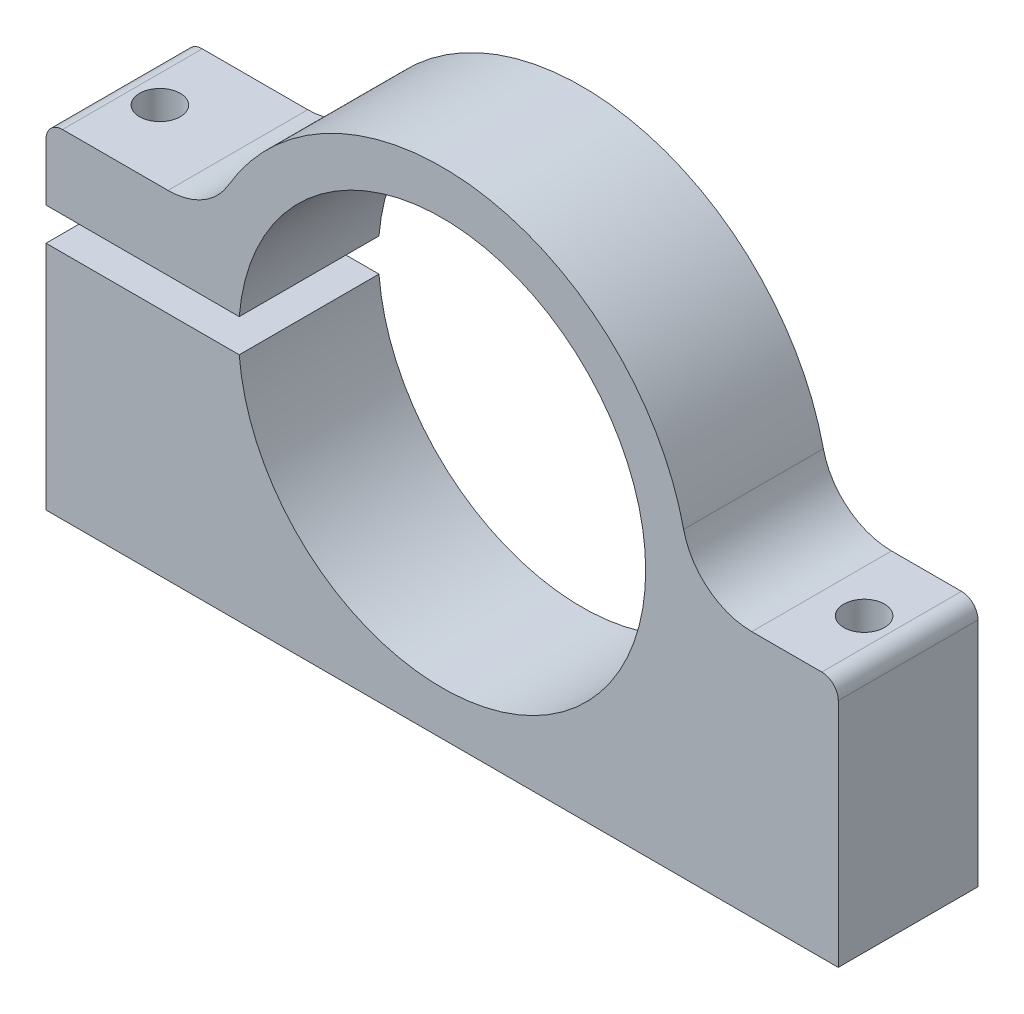
from build123d import *

# Parameters (mm, degrees)
BOSS_EXTRUDE1_DEPTH            = 12.7
CUT_EXTRUDE1_DEPTH             = 13.7
SKETCH3_W                      = 18.5
SKETCH3_H                      = 12.7
F_3_7_3_7_DIAMETER_HOLE1_D     = 3.7
F_3_7_3_7_DIAMETER_HOLE1_DEPTH = 6.7
F_3_7_3_7_DIAMETER_HOLE2_D     = 3.7
F_3_7_3_7_DIAMETER_HOLE2_DEPTH = 45
F_3_7_3_7_DIAMETER_HOLE3_D     = 3.7
F_3_7_3_7_DIAMETER_HOLE3_DEPTH = 45
FILLET1_R                      = 1.5
FILLET2_R                      = 6.35


with BuildPart() as part:
    # Sketch1 → Boss-Extrude1 (new body)
    with BuildSketch(Plane.XY.offset(6.35)):
        with BuildLine():
            Line((-20.952565475, 8.2), (-36, 8.2))
            Line((-36, 8.2), (-36, -22.5))
            Line((-36, -22.5), (36, -22.5))
            Line((36, -22.5), (36, 0))
            Line((36, 0), (22.5, 0))
            ThreePointArc((22.5, 0), (4.172366044, 22.109757158), (-20.952565475, 8.2))
        make_face()
    extrude(amount=-BOSS_EXTRUDE1_DEPTH)

    # Sketch2 → Cut-Extrude1 (cut, through all)
    with BuildSketch(Plane(origin=(0, 0, -6.35), x_dir=(-1, 0, 0), z_dir=(0, 0, -1))):
        with BuildLine():
            Line((36, 1.5), (18.439088915, 1.5))
            ThreePointArc((18.439088915, 1.5), (18.5, 0), (18.439088915, -1.5))
            Line((18.439088915, -1.5), (36, -1.5))
            Line((36, -1.5), (36, 1.5))
        make_face()
    extrude(amount=-CUT_EXTRUDE1_DEPTH, mode=Mode.SUBTRACT)

    # Sketch3 → Cut-Revolve1 (revolve, cut)
    with BuildSketch(Plane(origin=(0, 0, 0), x_dir=(1, 0, 0), z_dir=(0, 1, 0))):
        with Locations((9.25, 0)):
            Rectangle(SKETCH3_W, SKETCH3_H)
    revolve(axis=Axis((0, 0, -6.35), (0, 0, 1)), mode=Mode.SUBTRACT)

    # Ø3.7 (3.7) Diameter Hole1
    with Locations(Plane(origin=(0, 8.2, 0), x_dir=(1, 0, 0), z_dir=(0, 1, 0))):
        with Locations((-32, 0)):
            Hole(F_3_7_3_7_DIAMETER_HOLE1_D / 2, depth=F_3_7_3_7_DIAMETER_HOLE1_DEPTH)

    # Ø3.7 (3.7) Diameter Hole2
    with Locations(Plane(origin=(0, -22.5, 0), x_dir=(-1, 0, 0), z_dir=(0, -1, 0))):
        with Locations((32, 0)):
            Hole(F_3_7_3_7_DIAMETER_HOLE2_D / 2, depth=F_3_7_3_7_DIAMETER_HOLE2_DEPTH)

    # Ø3.7 (3.7) Diameter Hole3
    with Locations(Plane(origin=(0, -22.5, 0), x_dir=(-1, 0, 0), z_dir=(0, -1, 0))):
        with Locations((-32, 0)):
            Hole(F_3_7_3_7_DIAMETER_HOLE3_D / 2, depth=F_3_7_3_7_DIAMETER_HOLE3_DEPTH)

    # Fillet1
    fillet1_edges = [part.edges().sort_by_distance(p)[0] for p in [
        (36, 0, 0),
        (-36, 8.2, 0),
    ]]
    fillet(fillet1_edges, radius=FILLET1_R)

    # Fillet2
    fillet2_edges = [part.edges().sort_by_distance(p)[0] for p in [
        (22.5, 0, 0),
        (-20.952565475, 8.2, 0),
    ]]
    fillet(fillet2_edges, radius=FILLET2_R)


solid = part.part
